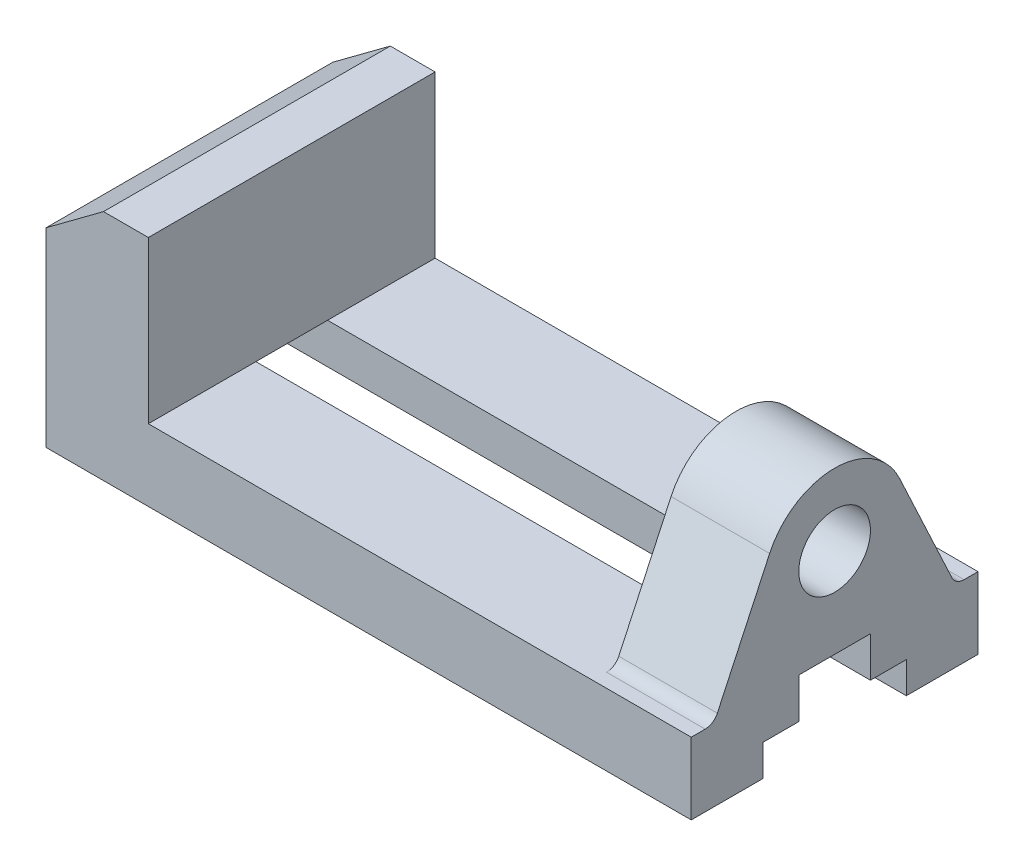
from build123d import *

# Parameters (mm, degrees)
BOSS_EXTRUDE1_DEPTH  = 32
SKETCH5_R            = 16
SKETCH5_R_2          = 8
BOSS_EXTRUDE2_DEPTH  = 22
CUT_EXTRUDE1_REACH   = 146
SKETCH9_R            = 3
CUT_EXTRUDE2_DEPTH   = 10
LPATTERN1_COUNT      = 2
LPATTERN1_PITCH      = 70
LPATTERN1_COUNT_DIR2 = 2
LPATTERN1_PITCH_DIR2 = 44


with BuildPart() as part:
    # Sketch3 → Boss-Extrude1 (new body, symmetric)
    with BuildSketch(Plane.XY):
        Polygon((0, 0), (0, 42.452913403), (12.839514692, 52), (22.839514692, 52), (22.839514692, 16), (144, 16), (144, 0), align=None)
    extrude(amount=BOSS_EXTRUDE1_DEPTH, both=True)

    # Sketch5 → Boss-Extrude2 (add)
    with BuildSketch(Plane(origin=(144, 0, 0), x_dir=(0, 0, -1), z_dir=(1, 0, 0))):
        with Locations((0, 36)):
            Circle(SKETCH5_R)
        with Locations((0, 36)):
            Circle(SKETCH5_R_2, mode=Mode.SUBTRACT)
        with BuildLine():
            ThreePointArc((16, 36), (-3.463033823, 20.379263886), (-14.500924593, 42.761892188))
            Line((-14.500924593, 42.761892188), (-26.172487288, 17.732145215))
            ThreePointArc((-26.172487288, 17.732145215), (-27.279511824, 16.469825663), (-28.891410649, 16))
            Line((-28.891410649, 16), (28.891410649, 16))
            ThreePointArc((28.891410649, 16), (27.279511824, 16.469825663), (26.172487288, 17.732145215))
            Line((26.172487288, 17.732145215), (14.500924593, 42.761892188))
            ThreePointArc((14.500924593, 42.761892188), (15.620736114, 39.463033823), (16, 36))
        make_face()
    extrude(amount=-BOSS_EXTRUDE2_DEPTH)

    # Sketch8 → Cut-Extrude1 (cut, up to next)
    with BuildSketch(Plane(origin=(144, 0, 0), x_dir=(0, 0, -1), z_dir=(1, 0, 0)), mode=Mode.PRIVATE) as cut_extrude1_sk1:
        Polygon((-16, 0), (-16, 7), (-8, 7), (-8, 16), (8, 16), (8, 7), (16, 7), (16, 0), align=None)
    cut_extrude1_tool1 = extrude(cut_extrude1_sk1.sketch, amount=-CUT_EXTRUDE1_REACH, mode=Mode.PRIVATE) & part.part
    add(cut_extrude1_tool1.solids().sort_by_distance((144, 6.630435, 0))[0], mode=Mode.SUBTRACT)

    # Sketch9 → Cut-Extrude2 (cut)
    with BuildSketch(Plane.XZ):
        with Locations((38, 22)):
            Circle(SKETCH9_R)
    cut_extrude2 = extrude(amount=-CUT_EXTRUDE2_DEPTH, mode=Mode.SUBTRACT)

    # LPattern1: Cut-Extrude2 2 × 2
    with Locations(*[(i * LPATTERN1_PITCH, 0, -j * LPATTERN1_PITCH_DIR2) for i in range(LPATTERN1_COUNT) for j in range(LPATTERN1_COUNT_DIR2) if (i, j) != (0, 0)]):
        add(cut_extrude2, mode=Mode.SUBTRACT)


solid = part.part
